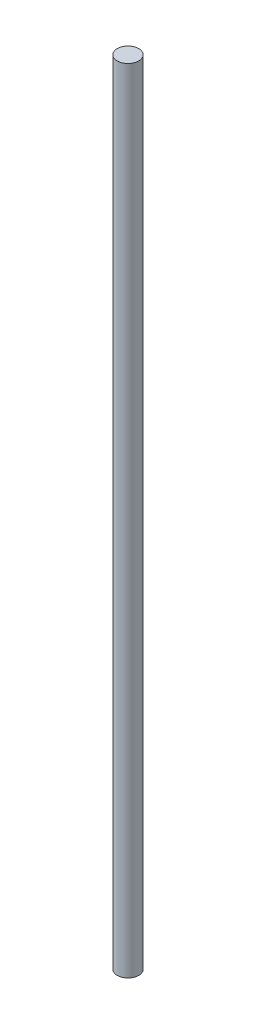
from build123d import *

# Parameters (mm, degrees)
SKETCH1_R           = 4
BOSS_EXTRUDE1_DEPTH = 295


with BuildPart() as part:
    # Sketch1 → Boss-Extrude1 (new body)
    with BuildSketch(Plane(origin=(0, 0, 0), x_dir=(1, 0, 0), z_dir=(0, 1, 0))):
        Circle(SKETCH1_R)
    extrude(amount=BOSS_EXTRUDE1_DEPTH)


solid = part.part
